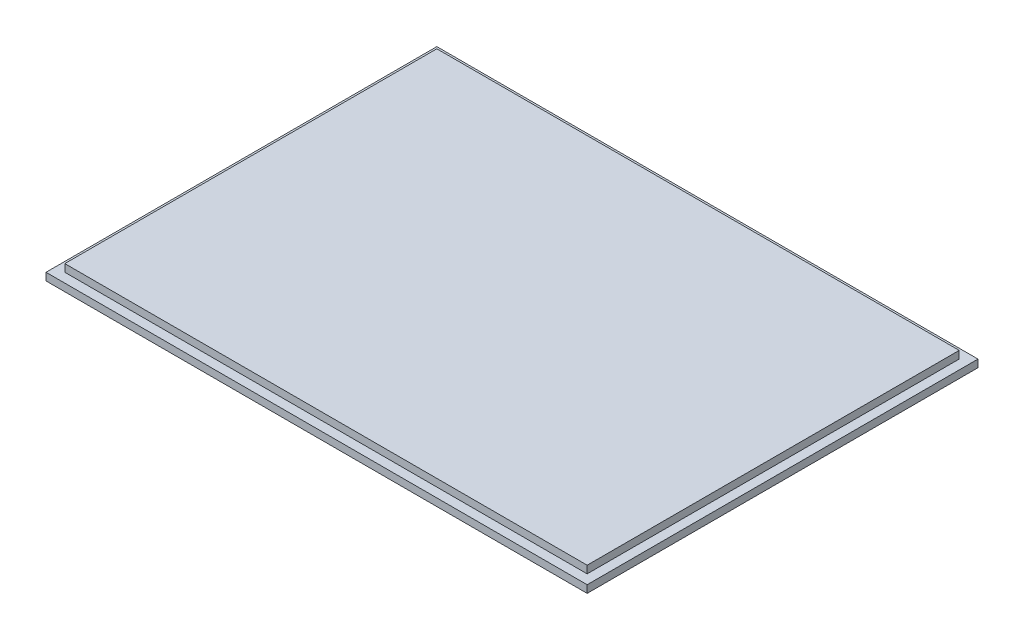
from build123d import *

# Parameters (mm, degrees)
CROQUIS1_W              = 72
CROQUIS1_H              = 52
CROQUIS1_W_2            = 69.5
CROQUIS1_H_2            = 49.5
SALIENTE_EXTRUIR1_DEPTH = 1
CROQUIS1_5_W            = 69.5
CROQUIS1_5_H            = 49.5
SALIENTE_EXTRUIR3_DEPTH = 2


with BuildPart() as part:
    # Croquis1 → Saliente-Extruir1 (new body)
    with BuildSketch(Plane(origin=(0, 0, 0), x_dir=(1, 0, 0), z_dir=(0, 1, 0))):
        with Locations((34.75, 24.75)):
            Rectangle(CROQUIS1_W, CROQUIS1_H)
        with Locations((34.75, 24.75)):
            Rectangle(CROQUIS1_W_2, CROQUIS1_H_2, mode=Mode.SUBTRACT)
    extrude(amount=SALIENTE_EXTRUIR1_DEPTH)

    # Croquis1_5 → Saliente-Extruir3 (add)
    with BuildSketch(Plane(origin=(0, 0, 0), x_dir=(1, 0, 0), z_dir=(0, 1, 0))):
        with Locations((34.75, 24.75)):
            Rectangle(CROQUIS1_5_W, CROQUIS1_5_H)
    extrude(amount=SALIENTE_EXTRUIR3_DEPTH)


solid = part.part
